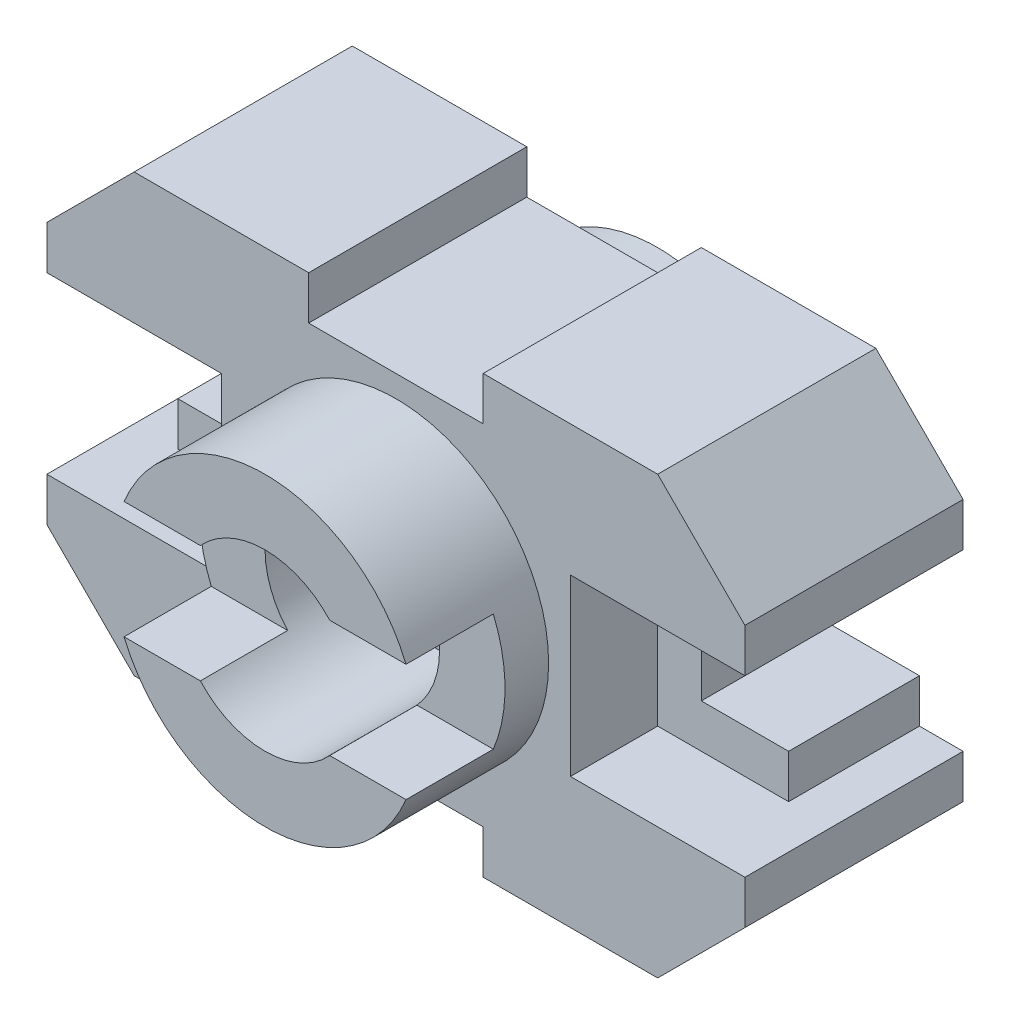
from build123d import *

# Parameters (mm, degrees)
BOSS_EXTRUDE1_DEPTH = 25
BOSS_EXTRUDE5_DEPTH = 15
SKETCH3_R           = 17.5
BOSS_EXTRUDE6_DEPTH = 15
SKETCH4_R           = 10
CUT_EXTRUDE1_DEPTH  = 20
SKETCH5_R           = 7.5
CUT_EXTRUDE2_DEPTH  = 80
CUT_EXTRUDE3_DEPTH  = 10
SKETCH7_R           = 17.5
BOSS_EXTRUDE7_DEPTH = 5
SKETCH8_R           = 7.5
CUT_EXTRUDE4_DEPTH  = 315


with BuildPart() as part:
    # Sketch1 → Boss-Extrude1 (new body)
    with BuildSketch(Plane.XY):
        Polygon((-60, 0), (-60, -5), (-50, -15), (-30, -15), (-30, -10), (-10, -10), (-10, -15), (10, -15), (20, -5), (20, 0), (0, 0), (0, 20), (20, 20), (20, 25), (10, 35), (-10, 35), (-10, 30), (-30, 30), (-30, 35), (-50, 35), (-60, 25), (-60, 20), (-40, 20), (-40, 0), align=None)
    extrude(amount=BOSS_EXTRUDE1_DEPTH)

    # Sketch2 → Boss-Extrude5 (add)
    with BuildSketch(Plane(origin=(0, 0, 0), x_dir=(-1, 0, 0), z_dir=(0, 0, -1))):
        Polygon((55, 20), (40, 20), (40, 0), (55, 0), (55, 5), (45, 5), (45, 15), (55, 15), align=None)
        Polygon((-15, 15), (-15, 20), (0, 20), (0, 0), (-15, 0), (-15, 5), (-5, 5), (-5, 15), align=None)
    extrude(amount=-BOSS_EXTRUDE5_DEPTH)

    # Sketch3 → Boss-Extrude6 (add)
    with BuildSketch(Plane.XY.offset(25)):
        with Locations((-20, 10)):
            Circle(SKETCH3_R)
    extrude(amount=BOSS_EXTRUDE6_DEPTH)

    # Sketch4 → Cut-Extrude1 (cut)
    with BuildSketch(Plane.XY.offset(40)):
        with Locations((-20, 10)):
            Circle(SKETCH4_R)
    extrude(amount=-CUT_EXTRUDE1_DEPTH, mode=Mode.SUBTRACT)

    # Sketch5 → Cut-Extrude2 (cut)
    with BuildSketch(Plane.XY.offset(20)):
        with Locations((-20, 10)):
            Circle(SKETCH5_R)
    extrude(amount=-CUT_EXTRUDE2_DEPTH, mode=Mode.SUBTRACT)

    # Sketch6 → Cut-Extrude3 (cut)
    with BuildSketch(Plane.XY.offset(40)):
        with BuildLine():
            Line((-36.160714286, 16.714261968), (-27.410714286, 16.714261968))
            ThreePointArc((-27.410714286, 16.714261968), (-30, 10), (-27.410714286, 3.285738032))
            Line((-27.410714286, 3.285738032), (-36.160714286, 3.285738032))
            ThreePointArc((-36.160714286, 3.285738032), (-37.5, 10), (-36.160714286, 16.714261968))
        make_face()
        with BuildLine():
            Line((-12.589285714, 16.714261968), (-3.839285714, 16.714261968))
            ThreePointArc((-3.839285714, 16.714261968), (-2.5, 10), (-3.839285714, 3.285738032))
            Line((-3.839285714, 3.285738032), (-12.589285714, 3.285738032))
            ThreePointArc((-12.589285714, 3.285738032), (-10, 10), (-12.589285714, 16.714261968))
        make_face()
    extrude(amount=-CUT_EXTRUDE3_DEPTH, mode=Mode.SUBTRACT)

    # Sketch7 → Boss-Extrude7 (add)
    with BuildSketch(Plane(origin=(0, 0, 0), x_dir=(-1, 0, 0), z_dir=(0, 0, -1))):
        with Locations(Location((20, 10, 0), (0, 0, 337.438671909))):
            Circle(SKETCH7_R)
    extrude(amount=BOSS_EXTRUDE7_DEPTH)

    # Sketch8 → Cut-Extrude4 (cut)
    with BuildSketch(Plane(origin=(0, 0, -5), x_dir=(-1, 0, 0), z_dir=(0, 0, -1))):
        with Locations(Location((20, 10, 0), (0, 0, 180))):
            Circle(SKETCH8_R)
    extrude(amount=-CUT_EXTRUDE4_DEPTH, mode=Mode.SUBTRACT)


solid = part.part
